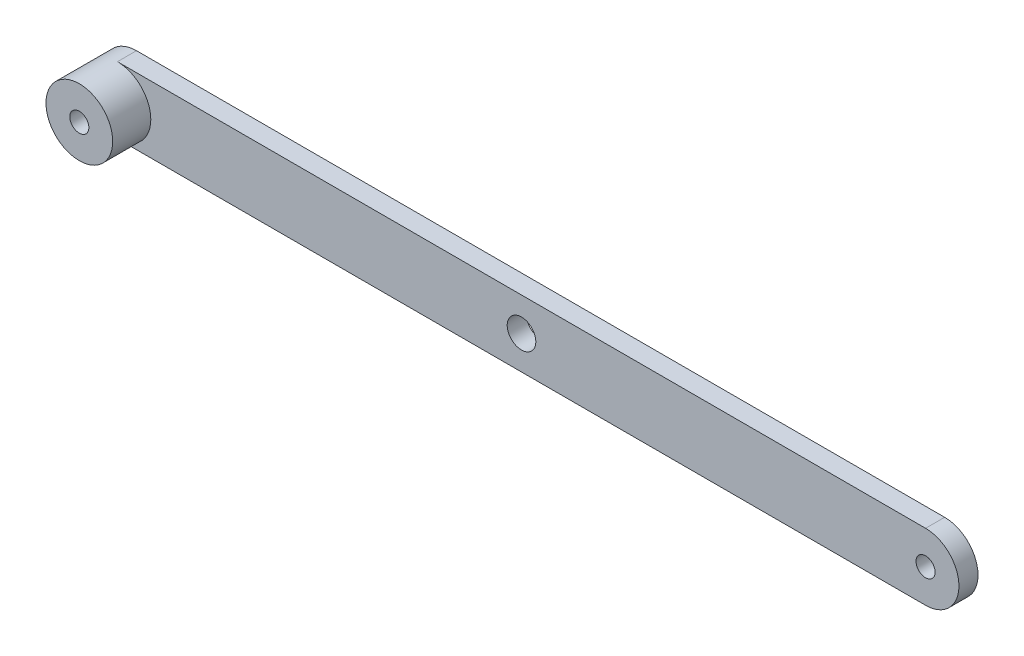
from build123d import *

# Parameters (mm, degrees)
CROQUIS1_R              = 5
CROQUIS1_R_2            = 7.5
SALIENTE_EXTRUIR1_DEPTH = 10
CROQUIS2_R              = 17.5
CROQUIS2_R_2            = 5
SALIENTE_EXTRUIR2_DEPTH = 20


with BuildPart() as part:
    # Croquis1 → Saliente-Extruir1 (new body)
    with BuildSketch(Plane.XY):
        with BuildLine():
            Line((-212, 17.5), (212, 17.5))
            ThreePointArc((212, 17.5), (229.5, 0), (212, -17.5))
            Line((212, -17.5), (-212, -17.5))
            ThreePointArc((-212, -17.5), (-229.5, 0), (-212, 17.5))
        make_face()
        with Locations((-212, 0)):
            Circle(CROQUIS1_R, mode=Mode.SUBTRACT)
        with Locations((212, 0)):
            Circle(CROQUIS1_R, mode=Mode.SUBTRACT)
        Circle(CROQUIS1_R_2, mode=Mode.SUBTRACT)
    extrude(amount=SALIENTE_EXTRUIR1_DEPTH)

    # Croquis2 → Saliente-Extruir2 (add)
    with BuildSketch(Plane.XY.offset(10)):
        with Locations((-212, 0)):
            Circle(CROQUIS2_R)
        with Locations((-212, 0)):
            Circle(CROQUIS2_R_2, mode=Mode.SUBTRACT)
    extrude(amount=SALIENTE_EXTRUIR2_DEPTH)


solid = part.part
